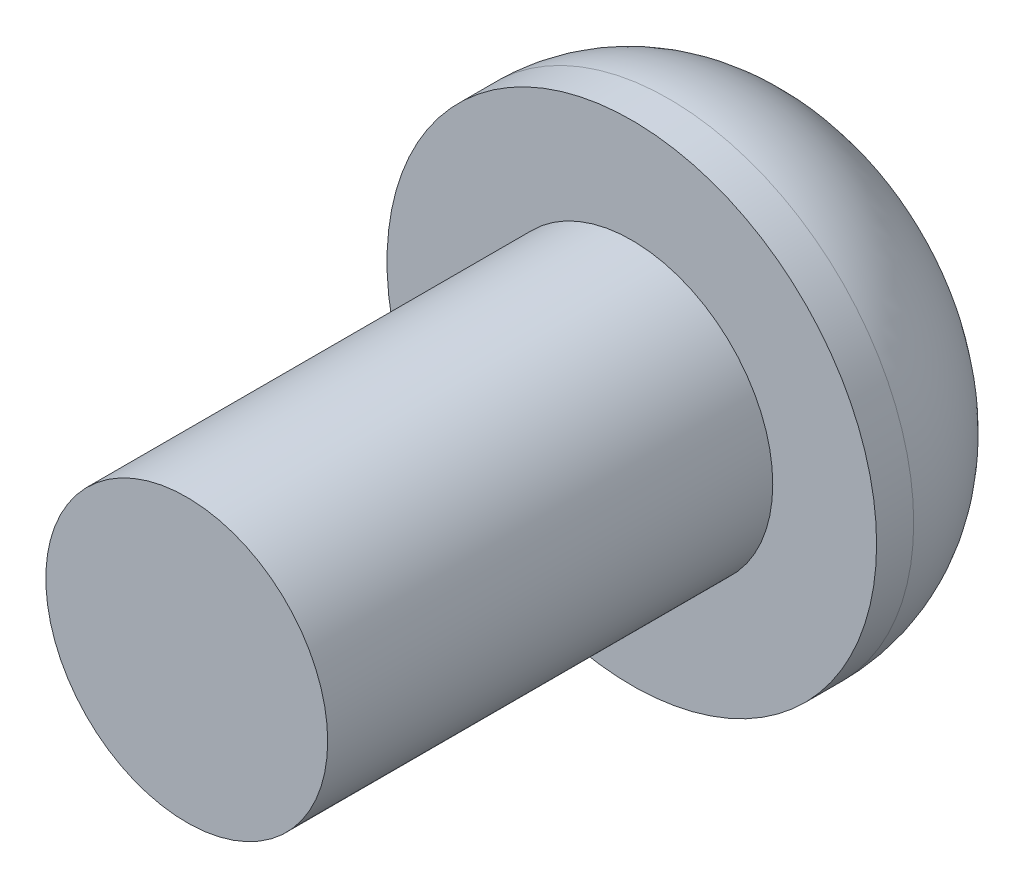
from build123d import *

# Parameters (mm, degrees)
SKETCH1_R           = 1.65
SKETCH1_R_2         = 0.95
BOSS_EXTRUDE1_DEPTH = 1.3
BOSS_EXTRUDE2_START = 1.3
SKETCH1_3_R         = 0.95
BOSS_EXTRUDE2_DEPTH = 3
FILLET1_R           = 1.05
SKETCH1_4_R         = 0.95
CUT_EXTRUDE1_DEPTH  = 1


with BuildPart() as part:
    # Sketch1 → Boss-Extrude1 (new body)
    with BuildSketch(Plane.XY):
        Circle(SKETCH1_R)
        Circle(SKETCH1_R_2, mode=Mode.SUBTRACT)
        Circle(SKETCH1_R_2)
    extrude(amount=BOSS_EXTRUDE1_DEPTH)

    # Sketch1_3 → Boss-Extrude2 (add)
    with BuildSketch(Plane.XY.offset(BOSS_EXTRUDE2_START)):
        Circle(SKETCH1_3_R)
    extrude(amount=BOSS_EXTRUDE2_DEPTH)

    # Fillet1
    fillet1_edges = [part.edges().sort_by_distance(p)[0] for p in [
        (-1.65, 0, 0),
    ]]
    fillet(fillet1_edges, radius=FILLET1_R)

    # Sketch1_4 → Cut-Extrude1 (cut)
    with BuildSketch(Plane.XY):
        Circle(SKETCH1_4_R)
    extrude(amount=CUT_EXTRUDE1_DEPTH, mode=Mode.SUBTRACT)


solid = part.part
